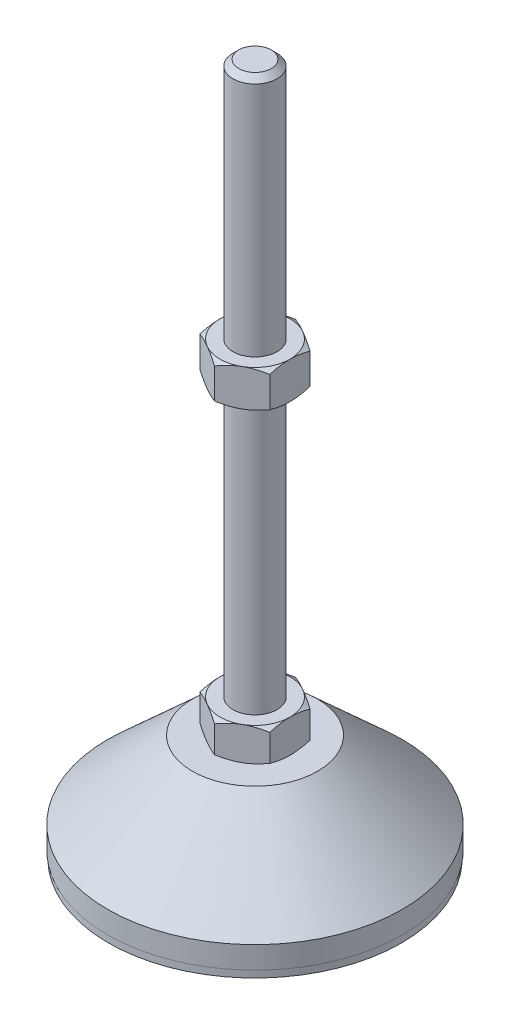
from build123d import *

# Parameters (mm, degrees)
EXTRUDE_1_DEPTH = 9
EXTRUDE_2_DEPTH = 10


with BuildPart() as part:
    # Эскиз1 → Повернуть1 (revolve)
    with BuildSketch(Plane.XY, mode=Mode.PRIVATE) as revolve_1_sk:
        Polygon((0, 0), (-39.8, 0), (-39.8, 2), (-40, 2), (-40, 8), (-17, 29), (-6, 29), (-6, 38), (-6, 186.4), (-4.4, 188), (0, 188), align=None)
    revolve(revolve_1_sk.sketch.rotate(Axis((0, 0, 0), (0, 1, 0)), 180), axis=Axis((0, 0, 0), (0, 1, 0)))  # turned: the seam where the file's is

    # Эскиз2 → Бобышка-Вытянуть1 (add)
    with BuildSketch(Plane(origin=(0, 29, 0), x_dir=(1, 0, 0), z_dir=(0, 1, 0))):
        Polygon((0, 10.969655115), (-9.5, 5.484827557), (-9.5, -5.484827557), (0, -10.969655115), (9.5, -5.484827557), (9.5, 5.484827557), align=None)
    extrude(amount=EXTRUDE_1_DEPTH)

    # Эскиз3 → Бобышка-Вытянуть2 (add)
    with BuildSketch(Plane(origin=(0, 112.2, 0), x_dir=(1, 0, 0), z_dir=(0, 1, 0))):
        Polygon((9.5, 5.484827557), (0, 10.969655115), (-9.5, 5.484827557), (-9.5, -5.484827557), (0, -10.969655115), (9.5, -5.484827557), align=None)
    extrude(amount=EXTRUDE_2_DEPTH)

    # Эскиз4 → Вырез-Повернуть2 (revolve, cut)
    with BuildSketch(Plane.XY, mode=Mode.PRIVATE) as cut_revolve_2_sk:
        Polygon((-18.160254038, 122.2), (-9.5, 122.2), (-18.160254038, 117.2), align=None)
        Polygon((-18.160254038, 112.2), (-18.160254038, 117.2), (-9.5, 112.2), align=None)
        Polygon((-17.294228634, 38), (-17.294228634, 33.5), (-9.5, 38), align=None)
        Polygon((-17.294228634, 33.5), (-17.294228634, 29), (-9.5, 29), align=None)
    revolve(cut_revolve_2_sk.sketch.rotate(Axis((0, 188, 0), (0, -1, 0)), 180), axis=Axis((0, 188, 0), (0, -1, 0)), mode=Mode.SUBTRACT)  # turned: the seam where the file's is


solid = part.part
